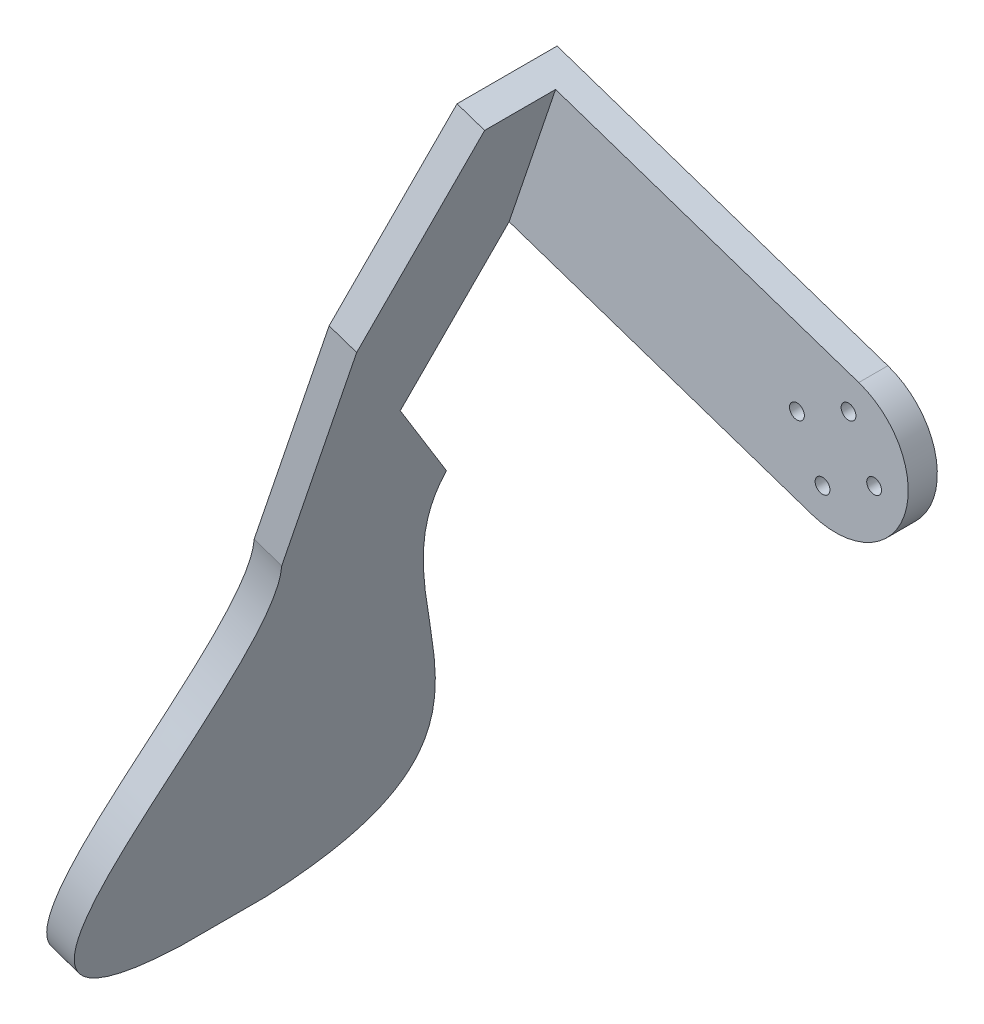
from build123d import *

# Parameters (mm, degrees)
SKETCH2_R           = 10
SKETCH2_R_2         = 1.275
BOSS_EXTRUDE1_DEPTH = 3
SKETCH3_R           = 1.275
BOSS_EXTRUDE2_DEPTH = 5
BOSS_EXTRUDE3_DEPTH = 5


with BuildPart() as part:
    # Sketch2 → Boss-Extrude1 (new body)
    with BuildSketch(Plane.XY):
        Circle(SKETCH2_R)
        with Locations((6.633008125, -2.236784122)):
            Circle(SKETCH2_R_2, mode=Mode.SUBTRACT)
        with Locations((-2.236784122, -6.633008125)):
            Circle(SKETCH2_R_2, mode=Mode.SUBTRACT)
        with Locations((-6.633008125, 2.236784122)):
            Circle(SKETCH2_R_2, mode=Mode.SUBTRACT)
        with Locations((2.236784122, 6.633008125)):
            Circle(SKETCH2_R_2, mode=Mode.SUBTRACT)
    extrude(amount=BOSS_EXTRUDE1_DEPTH)

    # Sketch3 → Boss-Extrude2 (add)
    with BuildSketch(Plane.XY.offset(3)):
        with BuildLine():
            Line((-3.994257361, -11.844657367), (-60.848612721, 7.327777966))
            Line((-60.848612721, 7.327777966), (-52.860097999, 31.0170927))
            Line((-52.860097999, 31.0170927), (3.994257361, 11.844657367))
            ThreePointArc((3.994257361, 11.844657367), (11.844657367, -3.994257361), (-3.994257361, -11.844657367))
        make_face()
        with Locations((6.633008125, -2.236784122)):
            Circle(SKETCH3_R, mode=Mode.SUBTRACT)
        with Locations((-2.236784122, -6.633008125)):
            Circle(SKETCH3_R, mode=Mode.SUBTRACT)
        with Locations((-6.633008125, 2.236784122)):
            Circle(SKETCH3_R, mode=Mode.SUBTRACT)
        with Locations((2.236784122, 6.633008125)):
            Circle(SKETCH3_R, mode=Mode.SUBTRACT)
    extrude(amount=-BOSS_EXTRUDE2_DEPTH)

    # Sketch4 → Boss-Extrude3 (add)
    with BuildSketch(Plane(origin=(-56.85435536, 19.172435333, 0), x_dir=(0.319540589, 0.947572589, 0), z_dir=(-0.947572589, 0.319540589, 0))):
        with BuildLine():
            Line((-62.942627893, -25.970573692), (-22.627671819, -25.970573692))
            Line((-22.627671819, -25.970573692), (12.5, -15.199288929))
            Line((12.5, -15.199288929), (12.5, -3))
            Line((12.5, -3), (-12.5, -3))
            Line((-12.5, -3), (-42.396291449, -12.167173681))
            Line((-42.396291449, -12.167173681), (-62.942627893, 2.349426308))
            add(Edge.make_bspline(
                [(-62.942627893, 2.349426308), (-87.492278411, -4.509248518), (-135.602543773, 45.42627104), (-139.208088658, -4.310573692)],
                knots=[0, 0, 0, 0, 1, 1, 1, 1], degree=3))
            Line((-139.208088658, -4.310573692), (-139.208088658, -19.310573692))
            add(Edge.make_bspline(
                [(-62.942627893, -25.970573692), (-87.492278411, -19.111898866), (-135.602543773, -69.047418424), (-139.208088658, -19.310573692)],
                knots=[0, 0, 0, 0, 1, 1, 1, 1], degree=3))
        make_face()
    extrude(amount=-BOSS_EXTRUDE3_DEPTH)


solid = part.part
